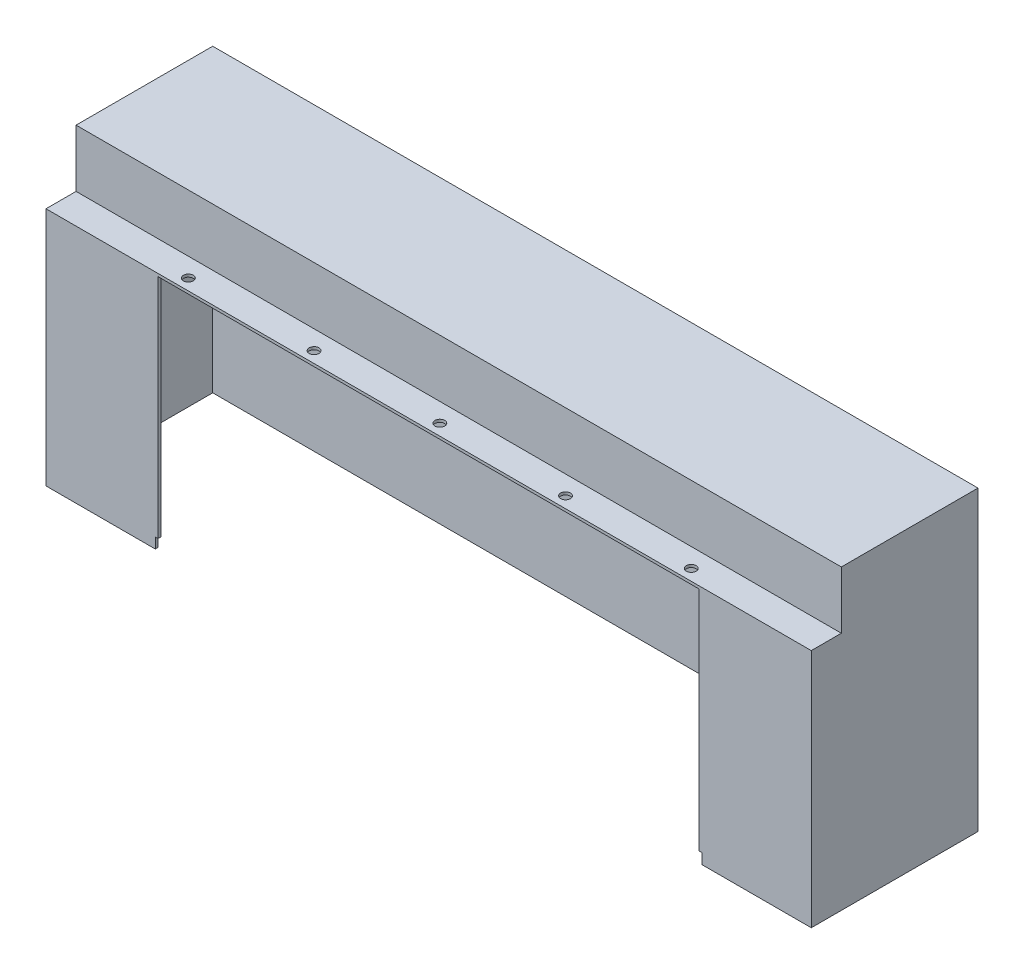
from build123d import *

# Parameters (mm, degrees)
ESBO_O1_W                = 700
ESBO_O1_H                = 210
RESSALTO_EXTRUS_O1_DEPTH = 2.5
RESSALTO_EXTRUS_O2_DEPTH = 150
CORTE_EXTRUS_O3_REACH    = 212
ESBO_O3_W                = 695
ESBO_O3_H                = 120
RESSALTO_EXTRUS_O5_DEPTH = 9.58
ESBO_O7_W                = 2.5
ESBO_O7_H                = 217.08
RESSALTO_EXTRUS_O6_DEPTH = 100
ESBO_O9_W                = 2.5
ESBO_O9_H                = 9.6
CORTE_EXTRUS_O4_DEPTH    = 9.5
ESBO_O10_R               = 4.5
CORTE_EXTRUS_O5_DEPTH    = 3
ESBO_O11_W               = 700
ESBO_O11_H               = 125
ESBO_O11_W_2             = 695
ESBO_O11_H_2             = 120
RESSALTO_EXTRUS_O7_DEPTH = 50
ESBO_O12_W               = 700
ESBO_O12_H               = 125
RESSALTO_EXTRUS_O8_DEPTH = 2.5


with BuildPart() as part:
    # Esboço1 → Ressalto-extrusão1 (new body)
    with BuildSketch(Plane.XY):
        Rectangle(ESBO_O1_W, ESBO_O1_H)
    extrude(amount=RESSALTO_EXTRUS_O1_DEPTH)

    # Esboço2 → Ressalto-extrusão2 (add)
    with BuildSketch(Plane.XY.offset(2.5)):
        Polygon((-347.5, 102.5), (-347.5, -105), (-350, -105), (-350, 105), (350, 105), (350, -105), (347.5, -105), (347.5, 102.5), align=None)
    extrude(amount=RESSALTO_EXTRUS_O2_DEPTH)

    # Esboço3 → Corte-extrusão3 (cut, up to next)
    with BuildSketch(Plane(origin=(0, 105, 0), x_dir=(1, 0, 0), z_dir=(0, 1, 0)), mode=Mode.PRIVATE) as corte_extrus_o3_sk1:
        with Locations((0, -62.5)):
            Rectangle(ESBO_O3_W, ESBO_O3_H)
    corte_extrus_o3_tool1 = extrude(corte_extrus_o3_sk1.sketch, amount=-CORTE_EXTRUS_O3_REACH, mode=Mode.PRIVATE) & part.part
    add(corte_extrus_o3_tool1.solids().sort_by_distance((0, 105, 62.5))[0], mode=Mode.SUBTRACT)

    # Esboço6 → Ressalto-extrusão5 (add)
    with BuildSketch(Plane.XZ.offset(105)):
        Polygon((350, 0), (350, 152.5), (347.5, 152.5), (347.5, 2.5), (-347.5, 2.5), (-347.5, 152.5), (-350, 152.5), (-350, 0), align=None)
    extrude(amount=RESSALTO_EXTRUS_O5_DEPTH)

    # Esboço7 → Ressalto-extrusão6 (add)
    with BuildSketch(Plane.ZY.offset(-347.5)):
        with Locations((151.25, -6.04)):
            Rectangle(ESBO_O7_W, ESBO_O7_H)
    ressalto_extrus_o6 = extrude(amount=RESSALTO_EXTRUS_O6_DEPTH)

    # Espelhar1: Ressalto-extrusão6 across plane
    add(ressalto_extrus_o6.mirror(Plane(origin=(0, 0, 0), x_dir=(0, 0, 1), z_dir=(1, 0, 0))))

    # Esboço9 → Corte-extrusão4 (cut)
    with BuildSketch(Plane.XY.offset(152.5)):
        with Locations((-248.75, -109.78)):
            Rectangle(ESBO_O9_W, ESBO_O9_H)
        with Locations((248.75, -109.78)):
            Rectangle(ESBO_O9_W, ESBO_O9_H)
    extrude(amount=-CORTE_EXTRUS_O4_DEPTH, mode=Mode.SUBTRACT)

    # Esboço10 → Corte-extrusão5 (cut)
    with BuildSketch(Plane(origin=(0, 105, 0), x_dir=(1, 0, 0), z_dir=(0, 1, 0))):
        with Locations((-230, -142.29)):
            Circle(ESBO_O10_R)
        with Locations((-115, -142.29)):
            Circle(ESBO_O10_R)
        with Locations((0, -142.29)):
            Circle(ESBO_O10_R)
        with Locations((115, -142.29)):
            Circle(ESBO_O10_R)
        with Locations((230, -142.29)):
            Circle(ESBO_O10_R)
    extrude(amount=-CORTE_EXTRUS_O5_DEPTH, mode=Mode.SUBTRACT)

    # Esboço11 → Ressalto-extrusão7 (add)
    with BuildSketch(Plane(origin=(0, 105, 0), x_dir=(1, 0, 0), z_dir=(0, 1, 0))):
        with Locations((0, -62.5)):
            Rectangle(ESBO_O11_W, ESBO_O11_H)
        with Locations((0, -62.5)):
            Rectangle(ESBO_O11_W_2, ESBO_O11_H_2, mode=Mode.SUBTRACT)
    extrude(amount=RESSALTO_EXTRUS_O7_DEPTH)

    # Esboço12 → Ressalto-extrusão8 (add)
    with BuildSketch(Plane(origin=(0, 155, 0), x_dir=(1, 0, 0), z_dir=(0, 1, 0))):
        with Locations((0, -62.5)):
            Rectangle(ESBO_O12_W, ESBO_O12_H)
    extrude(amount=RESSALTO_EXTRUS_O8_DEPTH)


solid = part.part
